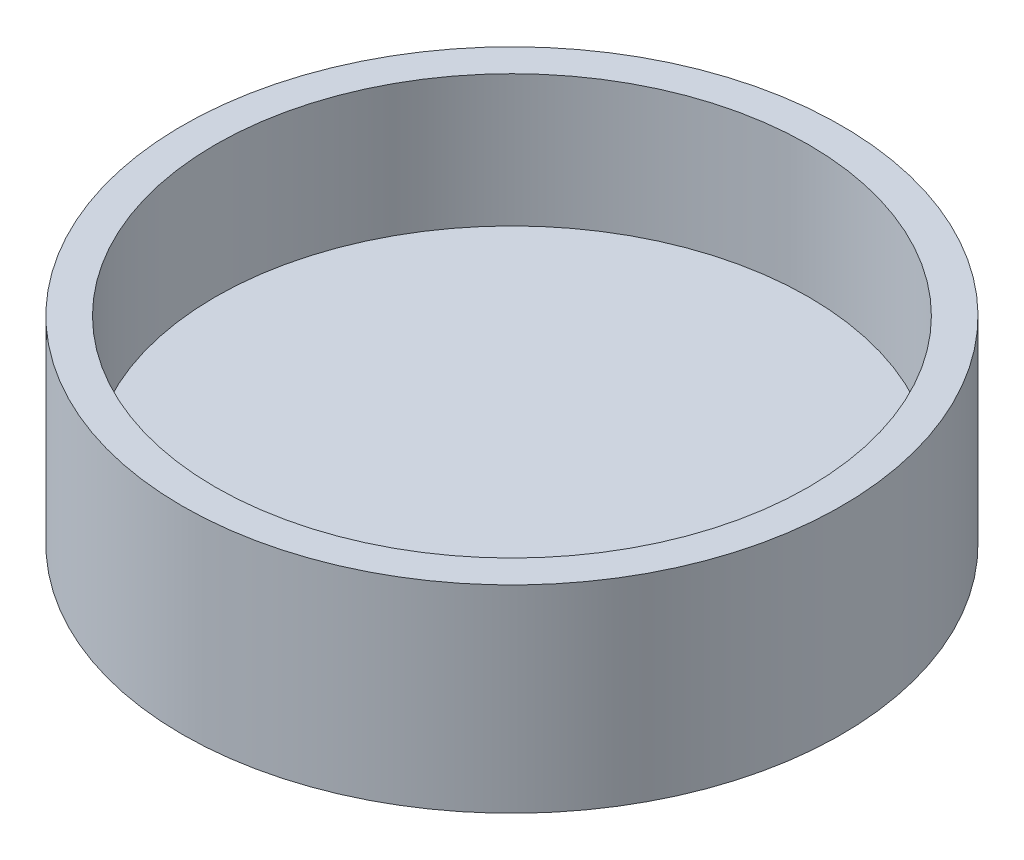
from build123d import *

# Parameters (mm, degrees)
ESBO_O1_R                = 50
RESSALTO_EXTRUS_O2_DEPTH = 10
ESBO_O2_R                = 50
ESBO_O2_R_2              = 45
RESSALTO_EXTRUS_O4_DEPTH = 20


with BuildPart() as part:
    # Esboço1 → Ressalto-extrusão2 (new body)
    with BuildSketch(Plane(origin=(0, 0, 0), x_dir=(1, 0, 0), z_dir=(0, 1, 0))):
        Circle(ESBO_O1_R)
    extrude(amount=RESSALTO_EXTRUS_O2_DEPTH)

    # Esboço2 → Ressalto-extrusão4 (add)
    with BuildSketch(Plane(origin=(0, 10, 0), x_dir=(1, 0, 0), z_dir=(0, 1, 0))):
        Circle(ESBO_O2_R)
        Circle(ESBO_O2_R_2, mode=Mode.SUBTRACT)
    extrude(amount=RESSALTO_EXTRUS_O4_DEPTH)


solid = part.part
